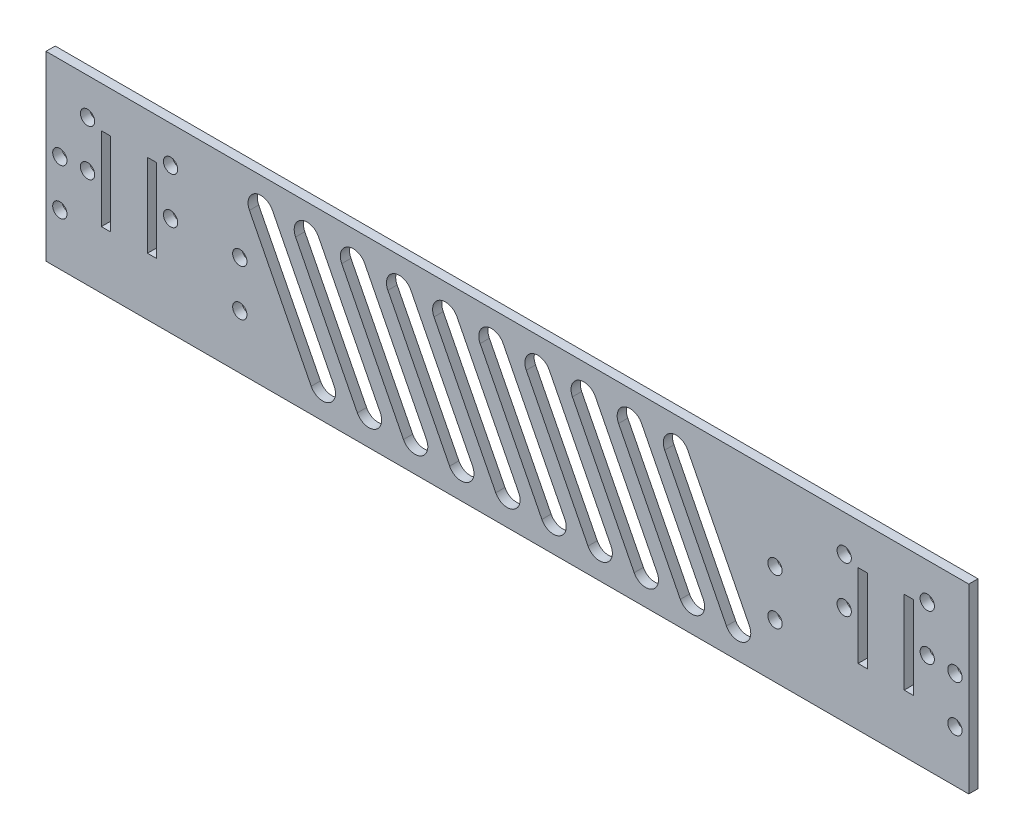
from build123d import *

# Parameters (mm, degrees)
SKETCH_1_W          = 200
SKETCH_1_H          = 39.4
SKETCH_1_R          = 1.55
SKETCH_1_W_2        = 2
SKETCH_1_H_2        = 18
EXTRUDE_1_DEPTH     = 2
CUT_EXTRUDE_1_DEPTH = 3


with BuildPart() as part:
    # 草图1 → 凸台-拉伸1 (new body)
    with BuildSketch(Plane.XY):
        Rectangle(SKETCH_1_W, SKETCH_1_H)
        with Locations((97, 1.43)):
            Circle(SKETCH_1_R, mode=Mode.SUBTRACT)
        with Locations((97, -8.57)):
            Circle(SKETCH_1_R, mode=Mode.SUBTRACT)
        with Locations((58, 2)):
            Circle(SKETCH_1_R, mode=Mode.SUBTRACT)
        with Locations((58, -8)):
            Circle(SKETCH_1_R, mode=Mode.SUBTRACT)
        with Locations((-97, 1.43)):
            Circle(SKETCH_1_R, mode=Mode.SUBTRACT)
        with Locations((-97, -8.57)):
            Circle(SKETCH_1_R, mode=Mode.SUBTRACT)
        with Locations((-58, -8)):
            Circle(SKETCH_1_R, mode=Mode.SUBTRACT)
        with Locations((-58, 2)):
            Circle(SKETCH_1_R, mode=Mode.SUBTRACT)
        with Locations((73, 11.8)):
            Circle(SKETCH_1_R, mode=Mode.SUBTRACT)
        with Locations((73, 1.8)):
            Circle(SKETCH_1_R, mode=Mode.SUBTRACT)
        with Locations((-73, 11.8)):
            Circle(SKETCH_1_R, mode=Mode.SUBTRACT)
        with Locations((-73, 1.8)):
            Circle(SKETCH_1_R, mode=Mode.SUBTRACT)
        with Locations((91, 11.8)):
            Circle(SKETCH_1_R, mode=Mode.SUBTRACT)
        with Locations((91, 1.8)):
            Circle(SKETCH_1_R, mode=Mode.SUBTRACT)
        with Locations((-91, 1.8)):
            Circle(SKETCH_1_R, mode=Mode.SUBTRACT)
        with Locations((-91, 11.8)):
            Circle(SKETCH_1_R, mode=Mode.SUBTRACT)
        with Locations((87, 1.8)):
            Rectangle(SKETCH_1_W_2, SKETCH_1_H_2, mode=Mode.SUBTRACT)
        with Locations((-87, 1.8)):
            Rectangle(SKETCH_1_W_2, SKETCH_1_H_2, mode=Mode.SUBTRACT)
        with Locations((77, 1.8)):
            Rectangle(SKETCH_1_W_2, SKETCH_1_H_2, mode=Mode.SUBTRACT)
        with Locations((-77, 1.8)):
            Rectangle(SKETCH_1_W_2, SKETCH_1_H_2, mode=Mode.SUBTRACT)
    extrude(amount=EXTRUDE_1_DEPTH)

    # 草图2 → 切除-拉伸1 (cut, through all)
    with BuildSketch(Plane.XY.offset(2)):
        with BuildLine():
            Line((-50.932586808, 14.42388858), (-37.550945645, -11.894165105))
            ThreePointArc((-37.550945645, -11.894165105), (-38.772782628, -15.643779248), (-42.522396771, -14.421942266))
            Line((-42.522396771, -14.421942266), (-55.904037934, 11.89611142))
            ThreePointArc((-55.904037934, 11.89611142), (-54.682200951, 15.645725563), (-50.932586808, 14.42388858))
        make_face()
        with BuildLine():
            Line((-40.932586808, 14.42388858), (-27.550945645, -11.894165105))
            ThreePointArc((-27.550945645, -11.894165105), (-28.772782628, -15.643779248), (-32.522396771, -14.421942266))
            Line((-32.522396771, -14.421942266), (-45.904037934, 11.89611142))
            ThreePointArc((-45.904037934, 11.89611142), (-44.682200951, 15.645725563), (-40.932586808, 14.42388858))
        make_face()
        with BuildLine():
            Line((-30.932586808, 14.42388858), (-17.550945645, -11.894165105))
            ThreePointArc((-17.550945645, -11.894165105), (-18.772782628, -15.643779248), (-22.522396771, -14.421942266))
            Line((-22.522396771, -14.421942266), (-35.904037934, 11.89611142))
            ThreePointArc((-35.904037934, 11.89611142), (-34.682200951, 15.645725563), (-30.932586808, 14.42388858))
        make_face()
        with BuildLine():
            Line((-20.932586808, 14.42388858), (-7.550945645, -11.894165105))
            ThreePointArc((-7.550945645, -11.894165105), (-8.772782628, -15.643779248), (-12.522396771, -14.421942266))
            Line((-12.522396771, -14.421942266), (-25.904037934, 11.89611142))
            ThreePointArc((-25.904037934, 11.89611142), (-24.682200951, 15.645725563), (-20.932586808, 14.42388858))
        make_face()
        with BuildLine():
            Line((-10.932586808, 14.42388858), (2.449054355, -11.894165105))
            ThreePointArc((2.449054355, -11.894165105), (1.227217372, -15.643779248), (-2.522396771, -14.421942266))
            Line((-2.522396771, -14.421942266), (-15.904037934, 11.89611142))
            ThreePointArc((-15.904037934, 11.89611142), (-14.682200951, 15.645725563), (-10.932586808, 14.42388858))
        make_face()
        with BuildLine():
            Line((-0.932586808, 14.42388858), (12.449054355, -11.894165105))
            ThreePointArc((12.449054355, -11.894165105), (11.227217372, -15.643779248), (7.477603229, -14.421942266))
            Line((7.477603229, -14.421942266), (-5.904037934, 11.89611142))
            ThreePointArc((-5.904037934, 11.89611142), (-4.682200951, 15.645725563), (-0.932586808, 14.42388858))
        make_face()
        with BuildLine():
            Line((9.067413192, 14.42388858), (22.449054355, -11.894165105))
            ThreePointArc((22.449054355, -11.894165105), (21.227217372, -15.643779248), (17.477603229, -14.421942266))
            Line((17.477603229, -14.421942266), (4.095962066, 11.89611142))
            ThreePointArc((4.095962066, 11.89611142), (5.317799049, 15.645725563), (9.067413192, 14.42388858))
        make_face()
        with BuildLine():
            Line((19.067413192, 14.42388858), (32.449054355, -11.894165105))
            ThreePointArc((32.449054355, -11.894165105), (31.227217372, -15.643779248), (27.477603229, -14.421942266))
            Line((27.477603229, -14.421942266), (14.095962066, 11.89611142))
            ThreePointArc((14.095962066, 11.89611142), (15.317799049, 15.645725563), (19.067413192, 14.42388858))
        make_face()
        with BuildLine():
            Line((29.067413192, 14.42388858), (42.449054355, -11.894165105))
            ThreePointArc((42.449054355, -11.894165105), (41.227217372, -15.643779248), (37.477603229, -14.421942266))
            Line((37.477603229, -14.421942266), (24.095962066, 11.89611142))
            ThreePointArc((24.095962066, 11.89611142), (25.317799049, 15.645725563), (29.067413192, 14.42388858))
        make_face()
        with BuildLine():
            Line((39.067413192, 14.42388858), (52.449054355, -11.894165105))
            ThreePointArc((52.449054355, -11.894165105), (51.227217372, -15.643779248), (47.477603229, -14.421942266))
            Line((47.477603229, -14.421942266), (34.095962066, 11.89611142))
            ThreePointArc((34.095962066, 11.89611142), (35.317799049, 15.645725563), (39.067413192, 14.42388858))
        make_face()
    extrude(amount=-CUT_EXTRUDE_1_DEPTH, mode=Mode.SUBTRACT)


solid = part.part
